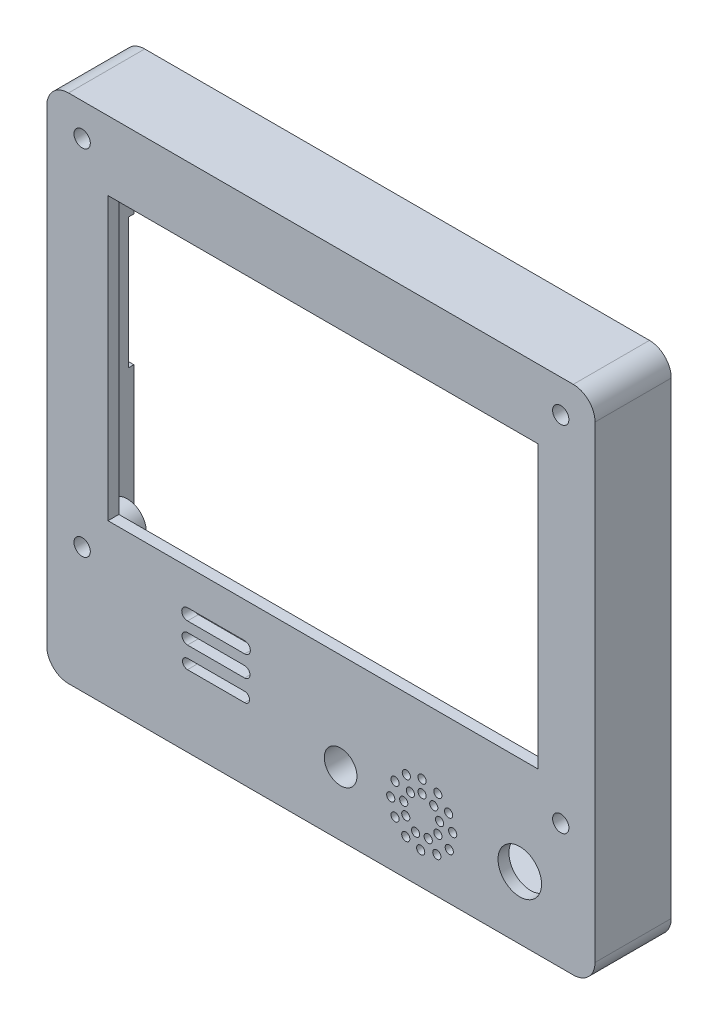
from build123d import *

# Parameters (mm, degrees)
SKETCH1_W           = 100.75
SKETCH1_H           = 94
SKETCH1_R           = 4
SKETCH1_R_2         = 0.75
BOSS_EXTRUDE1_DEPTH = 14
SKETCH2_W           = 96.749994904
SKETCH2_H           = 90.000003576
CUT_EXTRUDE1_DEPTH  = 12
SKETCH3_R           = 3.548963513
SKETCH3_R_2         = 3.408819902
SKETCH3_R_3         = 3.5
BOSS_EXTRUDE2_DEPTH = 6.3
SKETCH4_R           = 4
BOSS_EXTRUDE3_DEPTH = 6.3
SKETCH7_R           = 1.5
CUT_EXTRUDE2_DEPTH  = 10
SKETCH11_R          = 3
CUT_EXTRUDE3_DEPTH  = 10
SKETCH10_R          = 1.5
CUT_EXTRUDE4_DEPTH  = 10
SKETCH9_R           = 1.5
CUT_EXTRUDE5_DEPTH  = 10
SKETCH12_W          = 79
SKETCH12_H          = 51.75
CUT_EXTRUDE6_DEPTH  = 6.3
FILLET1_R           = 4
SKETCH13_W          = 1
SKETCH13_H          = 24
CUT_EXTRUDE7_DEPTH  = 3


with BuildPart() as part:
    # Sketch1 → Boss-Extrude1 (new body)
    with BuildSketch(Plane.XY):
        with Locations((5.613095238, -11.055404346)):
            Rectangle(SKETCH1_W, SKETCH1_H)
        with Locations((42.159546405, -46.524709499)):
            Circle(SKETCH1_R, mode=Mode.SUBTRACT)
        with Locations((18.44753625, -46.478480461)):
            Circle(SKETCH1_R_2, mode=Mode.SUBTRACT)
        with Locations((19.234631499, -43.590885312)):
            Circle(SKETCH1_R_2, mode=Mode.SUBTRACT)
        with Locations((21.306759983, -41.506641185)):
            Circle(SKETCH1_R_2, mode=Mode.SUBTRACT)
        with Locations((24.200000332, -40.756641185)):
            Circle(SKETCH1_R_2, mode=Mode.SUBTRACT)
        with Locations((27.10075415, -41.594119124)):
            Circle(SKETCH1_R_2, mode=Mode.SUBTRACT)
        with Locations((29.079295953, -43.730354454)):
            Circle(SKETCH1_R_2, mode=Mode.SUBTRACT)
        with Locations((26.35075415, -43.930808011)):
            Circle(SKETCH1_R_2, mode=Mode.SUBTRACT)
        with Locations((24.200000332, -43.085140439)):
            Circle(SKETCH1_R_2, mode=Mode.SUBTRACT)
        with Locations((22.056759983, -43.930808011)):
            Circle(SKETCH1_R_2, mode=Mode.SUBTRACT)
        with Locations((20.829643134, -45.984414142)):
            Circle(SKETCH1_R_2, mode=Mode.SUBTRACT)
        with Locations((21.208891166, -48.100122201)):
            Circle(SKETCH1_R_2, mode=Mode.SUBTRACT)
        with Locations((23.009299731, -49.814525249)):
            Circle(SKETCH1_R_2, mode=Mode.SUBTRACT)
        with Locations((25.331945715, -49.660785564)):
            Circle(SKETCH1_R_2, mode=Mode.SUBTRACT)
        with Locations((27.10075415, -48.100122201)):
            Circle(SKETCH1_R_2, mode=Mode.SUBTRACT)
        with Locations((27.425643307, -45.898634663)):
            Circle(SKETCH1_R_2, mode=Mode.SUBTRACT)
        with Locations((29.829295953, -46.454612718)):
            Circle(SKETCH1_R_2, mode=Mode.SUBTRACT)
        with Locations((29.201955135, -49.487574185)):
            Circle(SKETCH1_R_2, mode=Mode.SUBTRACT)
        with Locations((26.912976345, -51.413900689)):
            Circle(SKETCH1_R_2, mode=Mode.SUBTRACT)
        with Locations((23.949532439, -52.163900689)):
            Circle(SKETCH1_R_2, mode=Mode.SUBTRACT)
        with Locations((21.208891166, -51.413900689)):
            Circle(SKETCH1_R_2, mode=Mode.SUBTRACT)
        with Locations((19.234631499, -49.282190221)):
            Circle(SKETCH1_R_2, mode=Mode.SUBTRACT)
        with BuildLine():
            Line((-18.905494332, -35.031726566), (-8.405494332, -35.031726566))
            ThreePointArc((-8.405494332, -35.031726566), (-7.350829628, -36.08639127), (-8.405494332, -37.141055974))
            Line((-8.405494332, -37.141055974), (-18.905494332, -37.141055974))
            ThreePointArc((-18.905494332, -37.141055974), (-19.960159036, -36.08639127), (-18.905494332, -35.031726566))
        make_face(mode=Mode.SUBTRACT)
        with BuildLine():
            Line((-18.905494332, -39.000402281), (-8.405494332, -39.000402281))
            ThreePointArc((-8.405494332, -39.000402281), (-7.412807684, -39.993088929), (-8.405494332, -40.985775577))
            Line((-8.405494332, -40.985775577), (-18.905494332, -40.985775577))
            ThreePointArc((-18.905494332, -40.985775577), (-19.89818098, -39.993088929), (-18.905494332, -39.000402281))
        make_face(mode=Mode.SUBTRACT)
        with BuildLine():
            Line((-18.905494332, -43.093266368), (-8.405494332, -43.093266368))
            ThreePointArc((-8.405494332, -43.093266368), (-7.500570206, -43.998190495), (-8.405494332, -44.903114621))
            Line((-8.405494332, -44.903114621), (-18.905494332, -44.903114621))
            ThreePointArc((-18.905494332, -44.903114621), (-19.810418459, -43.998190495), (-18.905494332, -43.093266368))
        make_face(mode=Mode.SUBTRACT)
    extrude(amount=BOSS_EXTRUDE1_DEPTH)

    # Sketch2 → Cut-Extrude1 (cut)
    with BuildSketch(Plane(origin=(0, 0, 0), x_dir=(-1, 0, 0), z_dir=(0, 0, -1))):
        with Locations((-5.613093018, -11.047617438)):
            Rectangle(SKETCH2_W, SKETCH2_H)
    extrude(amount=-CUT_EXTRUDE1_DEPTH, mode=Mode.SUBTRACT)

    # Sketch3 → Boss-Extrude2 (add)
    with BuildSketch(Plane(origin=(0, 0, 12), x_dir=(-1, 0, 0), z_dir=(0, 0, -1))):
        with Locations((-49.488095238, 29.944595654)):
            Circle(SKETCH3_R)
        with Locations((38.261904762, 29.944595654)):
            Circle(SKETCH3_R_2)
        with Locations((38.261904762, -35.055404346)):
            Circle(SKETCH3_R_3)
        with Locations((-49.488095238, -35.055404346)):
            Circle(SKETCH3_R_3)
    extrude(amount=BOSS_EXTRUDE2_DEPTH)

    # Sketch4 → Boss-Extrude3 (add)
    with BuildSketch(Plane(origin=(0, 0, 12), x_dir=(-1, 0, 0), z_dir=(0, 0, -1))):
        with Locations((-9.238095238, -46.305404346)):
            Circle(SKETCH4_R)
    extrude(amount=BOSS_EXTRUDE3_DEPTH)

    # Sketch7 → Cut-Extrude2 (cut)
    with BuildSketch(Plane(origin=(0, 0, 5.7), x_dir=(-1, 0, 0), z_dir=(0, 0, -1))):
        with Locations((-49.68373898, 29.928867)):
            Circle(SKETCH7_R)
    extrude(amount=-CUT_EXTRUDE2_DEPTH, mode=Mode.SUBTRACT)

    # Sketch11 → Cut-Extrude3 (cut)
    with BuildSketch(Plane(origin=(0, 0, 5.7), x_dir=(-1, 0, 0), z_dir=(0, 0, -1))):
        with Locations((-9.238095238, -46.305404346)):
            Circle(SKETCH11_R)
    extrude(amount=-CUT_EXTRUDE3_DEPTH, mode=Mode.SUBTRACT)

    # Sketch10 → Cut-Extrude4 (cut)
    with BuildSketch(Plane(origin=(0, 0, 5.7), x_dir=(-1, 0, 0), z_dir=(0, 0, -1))):
        with Locations((-49.686899023, -35.059761001)):
            Circle(SKETCH10_R)
    extrude(amount=-CUT_EXTRUDE4_DEPTH, mode=Mode.SUBTRACT)

    # Sketch9 → Cut-Extrude5 (cut)
    with BuildSketch(Plane(origin=(0, 0, 5.7), x_dir=(-1, 0, 0), z_dir=(0, 0, -1))):
        with Locations((38.261904762, 29.944595654)):
            Circle(SKETCH9_R)
        with Locations((38.261904762, -35.055404346)):
            Circle(SKETCH9_R)
    extrude(amount=-CUT_EXTRUDE5_DEPTH, mode=Mode.SUBTRACT)

    # Sketch12 → Cut-Extrude6 (cut)
    with BuildSketch(Plane(origin=(0, 0, 12), x_dir=(-1, 0, 0), z_dir=(0, 0, -1))):
        with Locations((-5.988095238, -2.630404346)):
            Rectangle(SKETCH12_W, SKETCH12_H)
    extrude(amount=-CUT_EXTRUDE6_DEPTH, mode=Mode.SUBTRACT)

    # Fillet1
    fillet1_edges = [part.edges().sort_by_distance(p)[0] for p in [
        (-44.761904762, 35.944595654, 7),
        (55.988095238, 35.944595654, 7),
        (55.988095238, -58.055404346, 7),
        (-44.761904762, -58.055404346, 7),
    ]]
    fillet(fillet1_edges, radius=FILLET1_R)

    # Sketch13 → Cut-Extrude7 (cut)
    with BuildSketch(Plane.ZY.offset(44.761904762)):
        with Locations((0.5, -3.305404346)):
            Rectangle(SKETCH13_W, SKETCH13_H)
    extrude(amount=-CUT_EXTRUDE7_DEPTH, mode=Mode.SUBTRACT)


solid = part.part
